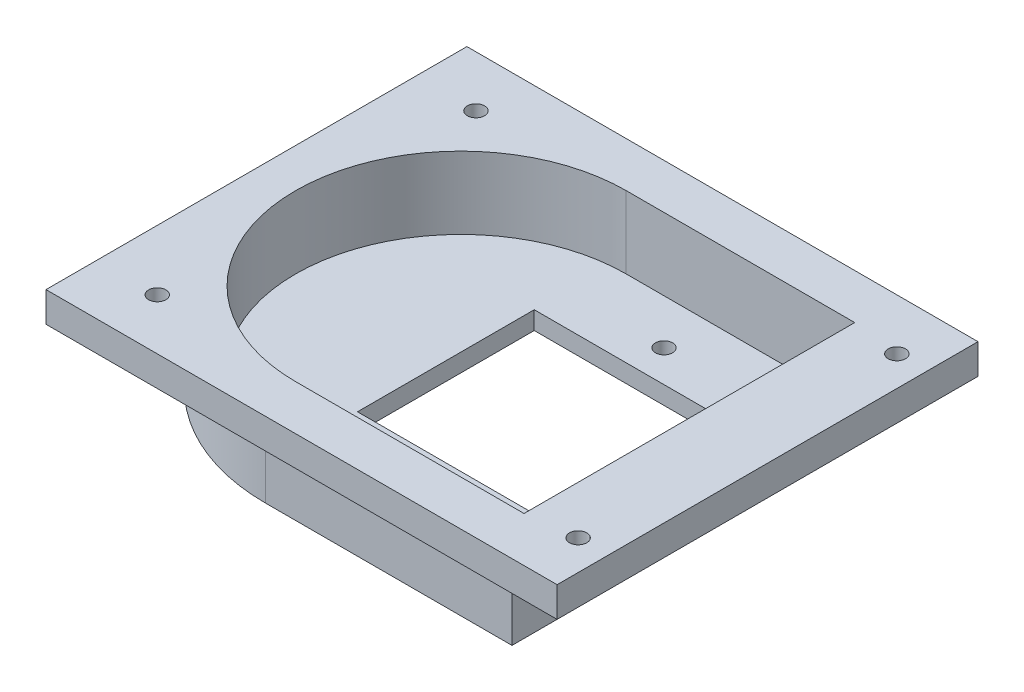
from build123d import *

# Parameters (mm, degrees)
CROQUIS1_W              = 85
CROQUIS1_H              = 70
SALIENTE_EXTRUIR1_DEPTH = 5
SALIENTE_EXTRUIR2_DEPTH = 10
CORTAR_EXTRUIR1_DEPTH   = 12
CROQUIS6_W              = 40.5
CROQUIS6_H              = 29.4
CORTAR_EXTRUIR2_DEPTH   = 16
CROQUIS7_R              = 1.435
CORTAR_EXTRUIR3_DEPTH   = 16
CROQUIS8_R              = 1.435
CORTAR_EXTRUIR4_DEPTH   = 6


with BuildPart() as part:
    # Croquis1 → Saliente-Extruir1 (new body)
    with BuildSketch(Plane(origin=(0, 0, 0), x_dir=(1, 0, 0), z_dir=(0, 1, 0))):
        Rectangle(CROQUIS1_W, CROQUIS1_H)
    extrude(amount=SALIENTE_EXTRUIR1_DEPTH)

    # Croquis3 → Saliente-Extruir2 (add)
    with BuildSketch(Plane(origin=(0, 0, 0), x_dir=(-1, 0, 0), z_dir=(0, -1, 0))):
        with BuildLine():
            Line((8.5, 32.5), (-32.5, 32.5))
            Line((-32.5, 32.5), (-32.5, -32.5))
            Line((-32.5, -32.5), (8.5, -32.5))
            ThreePointArc((8.5, -32.5), (41, 0), (8.5, 32.5))
        make_face()
    extrude(amount=SALIENTE_EXTRUIR2_DEPTH)

    # Croquis4 → Cortar-Extruir1 (cut)
    with BuildSketch(Plane(origin=(0, 5, 0), x_dir=(1, 0, 0), z_dir=(0, 1, 0))):
        with BuildLine():
            Line((-8.5, 27.5), (29.5, 27.5))
            Line((29.5, 27.5), (29.5, -27.5))
            Line((29.5, -27.5), (-8.5, -27.5))
            ThreePointArc((-8.5, -27.5), (-36, 0), (-8.5, 27.5))
        make_face()
    extrude(amount=-CORTAR_EXTRUIR1_DEPTH, mode=Mode.SUBTRACT)

    # Croquis6 → Cortar-Extruir2 (cut, through all)
    with BuildSketch(Plane.XZ.offset(10)):
        with Locations((9.25, 0)):
            Rectangle(CROQUIS6_W, CROQUIS6_H)
    extrude(amount=-CORTAR_EXTRUIR2_DEPTH, mode=Mode.SUBTRACT)

    # Croquis7 → Cortar-Extruir3 (cut, through all)
    with BuildSketch(Plane(origin=(0, -10, 0), x_dir=(-1, 0, 0), z_dir=(0, -1, 0))):
        with Locations((-5.28, -20)):
            Circle(CROQUIS7_R)
        with Locations((-5.28, 20)):
            Circle(CROQUIS7_R)
    extrude(amount=-CORTAR_EXTRUIR3_DEPTH, mode=Mode.SUBTRACT)

    # Croquis8 → Cortar-Extruir4 (cut, through all)
    with BuildSketch(Plane(origin=(0, 0, 0), x_dir=(-1, 0, 0), z_dir=(0, -1, 0))):
        with Locations((32.5, -26.5)):
            Circle(CROQUIS8_R)
        with Locations((-37.5, -26.5)):
            Circle(CROQUIS8_R)
        with Locations((-37.5, 26.5)):
            Circle(CROQUIS8_R)
        with Locations((32.5, 26.5)):
            Circle(CROQUIS8_R)
    extrude(amount=-CORTAR_EXTRUIR4_DEPTH, mode=Mode.SUBTRACT)


solid = part.part
